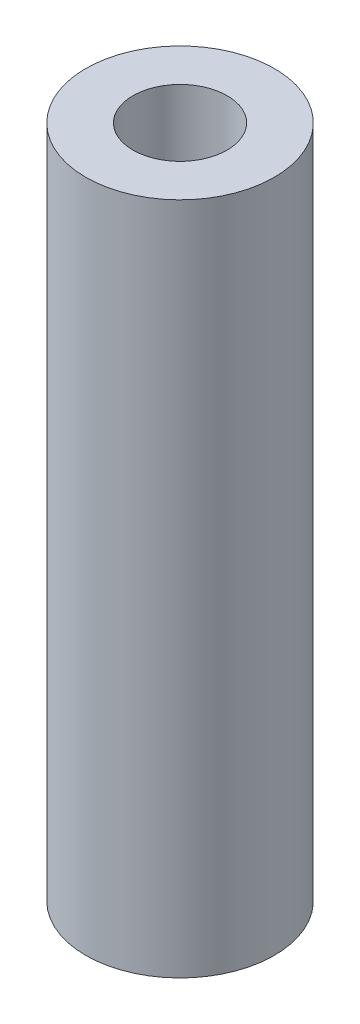
from build123d import *

# Parameters (mm, degrees)
SKETCH1_R           = 4
SKETCH1_R_2         = 2
BOSS_EXTRUDE1_DEPTH = 28.6


with BuildPart() as part:
    # Sketch1 → Boss-Extrude1 (new body)
    with BuildSketch(Plane(origin=(0, 0, 0), x_dir=(1, 0, 0), z_dir=(0, 1, 0))):
        Circle(SKETCH1_R)
        Circle(SKETCH1_R_2, mode=Mode.SUBTRACT)
    extrude(amount=BOSS_EXTRUDE1_DEPTH)


solid = part.part
